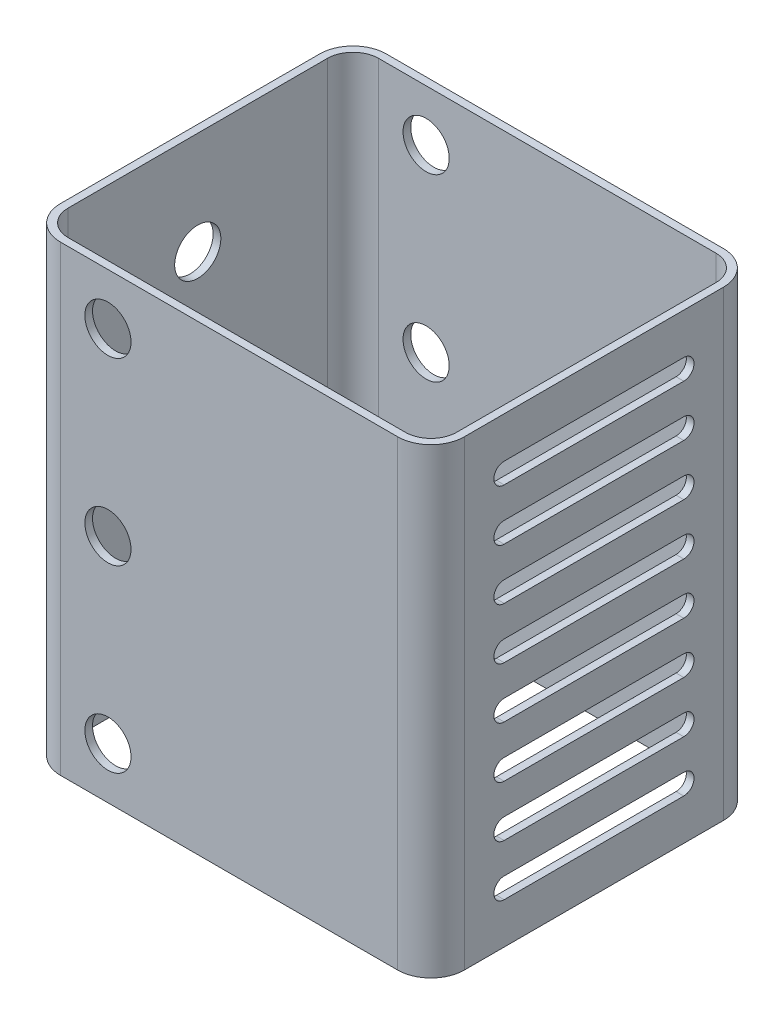
from build123d import *

# Parameters (mm, degrees)
BOSS_EXTRUDE1_DEPTH = 90
SKETCH2_R           = 4.5
CUT_EXTRUDE1_DEPTH  = 17
SKETCH3_R           = 4.5
CUT_EXTRUDE2_DEPTH  = 95
CUT_EXTRUDE3_DEPTH  = 29


with BuildPart() as part:
    # Sketch1 → Boss-Extrude1 (new body)
    with BuildSketch(Plane(origin=(0, 0, 0), x_dir=(1, 0, 0), z_dir=(0, 1, 0))):
        with BuildLine():
            Line((-32.85, -31.75), (32.85, -31.75))
            ThreePointArc((32.85, -31.75), (37.446194078, -29.846194078), (39.35, -25.25))
            Line((39.35, -25.25), (39.35, 25.25))
            ThreePointArc((39.35, 25.25), (37.446194078, 29.846194078), (32.85, 31.75))
            Line((32.85, 31.75), (-32.85, 31.75))
            ThreePointArc((-32.85, 31.75), (-37.446194078, 29.846194078), (-39.35, 25.25))
            Line((-39.35, 25.25), (-39.35, -25.25))
            ThreePointArc((-39.35, -25.25), (-37.446194078, -29.846194078), (-32.85, -31.75))
        make_face()
        with BuildLine():
            Line((-32.85, -30.25), (32.85, -30.25))
            ThreePointArc((32.85, -30.25), (36.385533906, -28.785533906), (37.85, -25.25))
            Line((37.85, -25.25), (37.85, 25.25))
            ThreePointArc((37.85, 25.25), (36.385533906, 28.785533906), (32.85, 30.25))
            Line((32.85, 30.25), (-32.85, 30.25))
            ThreePointArc((-32.85, 30.25), (-36.385533906, 28.785533906), (-37.85, 25.25))
            Line((-37.85, 25.25), (-37.85, -25.25))
            ThreePointArc((-37.85, -25.25), (-36.385533906, -28.785533906), (-32.85, -30.25))
        make_face(mode=Mode.SUBTRACT)
    extrude(amount=BOSS_EXTRUDE1_DEPTH)

    # Sketch2 → Cut-Extrude1 (cut)
    with BuildSketch(Plane.ZY.offset(34.75)):
        with Locations((0, 70)):
            Circle(SKETCH2_R)
        with Locations((0, 20)):
            Circle(SKETCH2_R)
    extrude(amount=CUT_EXTRUDE1_DEPTH, mode=Mode.SUBTRACT)

    # Sketch3 → Cut-Extrude2 (cut)
    with BuildSketch(Plane.XY.offset(32.25)):
        with Locations((-23.6, 80)):
            Circle(SKETCH3_R)
        with Locations((-23.6, 10)):
            Circle(SKETCH3_R)
        with Locations((-23.6, 45)):
            Circle(SKETCH3_R)
    extrude(amount=-CUT_EXTRUDE2_DEPTH, mode=Mode.SUBTRACT)

    # Sketch4 → Cut-Extrude3 (cut)
    with BuildSketch(Plane(origin=(34.75, 0, 0), x_dir=(0, 0, -1), z_dir=(1, 0, 0))):
        with BuildLine():
            Line((-17.5, 82), (17.5, 82))
            ThreePointArc((17.5, 82), (19.5, 80), (17.5, 78))
            Line((17.5, 78), (-17.5, 78))
            ThreePointArc((-17.5, 78), (-19.5, 80), (-17.5, 82))
        make_face()
        with BuildLine():
            Line((-17.5, 72), (17.5, 72))
            ThreePointArc((17.5, 72), (19.5, 70), (17.5, 68))
            Line((17.5, 68), (-17.5, 68))
            ThreePointArc((-17.5, 68), (-19.5, 70), (-17.5, 72))
        make_face()
        with BuildLine():
            Line((-17.5, 62), (17.5, 62))
            ThreePointArc((17.5, 62), (19.5, 60), (17.5, 58))
            Line((17.5, 58), (-17.5, 58))
            ThreePointArc((-17.5, 58), (-19.5, 60), (-17.5, 62))
        make_face()
        with BuildLine():
            Line((-17.5, 52), (17.5, 52))
            ThreePointArc((17.5, 52), (19.5, 50), (17.5, 48))
            Line((17.5, 48), (-17.5, 48))
            ThreePointArc((-17.5, 48), (-19.5, 50), (-17.5, 52))
        make_face()
        with BuildLine():
            Line((-17.5, 42), (17.5, 42))
            ThreePointArc((17.5, 42), (19.5, 40), (17.5, 38))
            Line((17.5, 38), (-17.5, 38))
            ThreePointArc((-17.5, 38), (-19.5, 40), (-17.5, 42))
        make_face()
        with BuildLine():
            Line((-17.5, 32), (17.5, 32))
            ThreePointArc((17.5, 32), (19.5, 30), (17.5, 28))
            Line((17.5, 28), (-17.5, 28))
            ThreePointArc((-17.5, 28), (-19.5, 30), (-17.5, 32))
        make_face()
        with BuildLine():
            Line((-17.5, 22), (17.5, 22))
            ThreePointArc((17.5, 22), (19.5, 20), (17.5, 18))
            Line((17.5, 18), (-17.5, 18))
            ThreePointArc((-17.5, 18), (-19.5, 20), (-17.5, 22))
        make_face()
        with BuildLine():
            Line((-17.5, 12), (17.5, 12))
            ThreePointArc((17.5, 12), (19.5, 10), (17.5, 8))
            Line((17.5, 8), (-17.5, 8))
            ThreePointArc((-17.5, 8), (-19.5, 10), (-17.5, 12))
        make_face()
    extrude(amount=CUT_EXTRUDE3_DEPTH, mode=Mode.SUBTRACT)


solid = part.part
